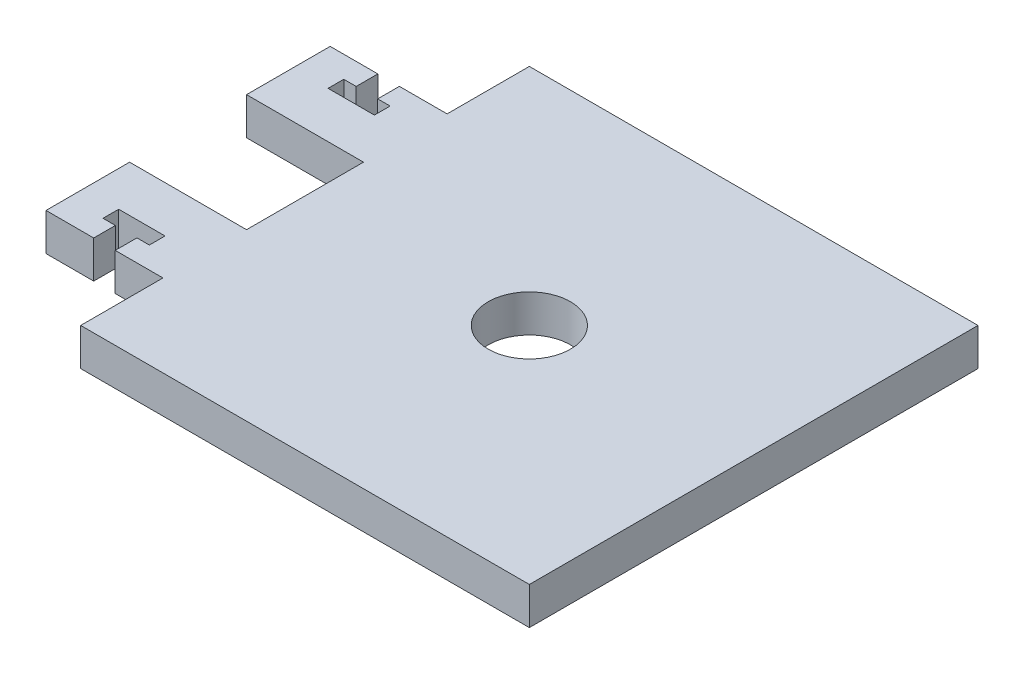
from build123d import *

# Parameters (mm, degrees)
SKETCH1_R           = 6.985
BOSS_EXTRUDE1_DEPTH = 6.35


with BuildPart() as part:
    # Sketch1 → Boss-Extrude1 (new body)
    with BuildSketch(Plane(origin=(0, 0, 0), x_dir=(1, 0, 0), z_dir=(0, 1, 0))):
        Polygon((-38.1, -38.1), (38.1, -38.1), (38.1, 38.1), (-38.1, 38.1), (-38.1, 24.13), (-46.2026, 24.13), (-46.2026, 20.447), (-44.0944, 20.447), (-44.0944, 17.78), (-51.9684, 17.78), (-51.9684, 20.447), (-49.8602, 20.447), (-49.8602, 24.13), (-57.9628, 24.13), (-57.9628, 9.9314), (-38.1, 9.9314), (-38.1, -9.9314), (-57.9628, -9.9314), (-57.9628, -24.13), (-49.8602, -24.13), (-49.8602, -20.447), (-51.9684, -20.447), (-51.9684, -17.78), (-44.0944, -17.78), (-44.0944, -20.447), (-46.2026, -20.447), (-46.2026, -24.13), (-38.1, -24.13), align=None)
        Circle(SKETCH1_R, mode=Mode.SUBTRACT)
    extrude(amount=-BOSS_EXTRUDE1_DEPTH)


solid = part.part
